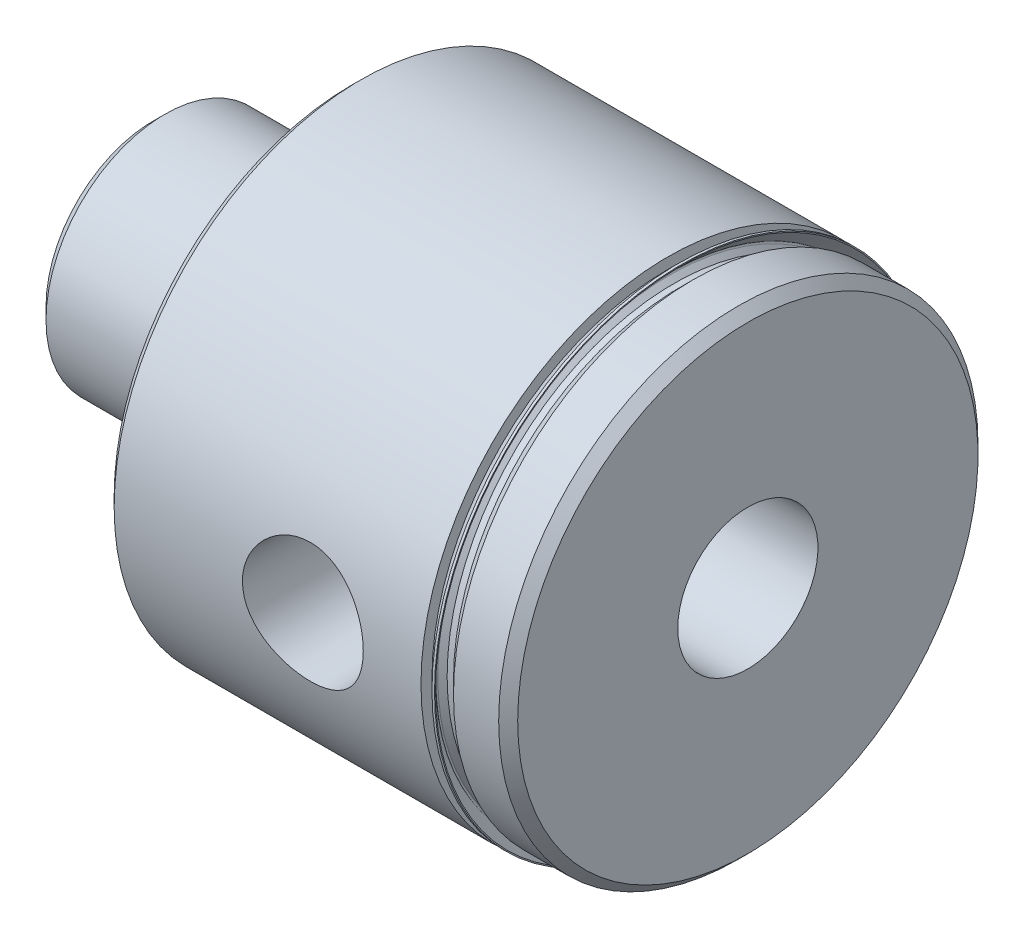
from build123d import *


with BuildPart() as part:
    # Sketch1 → Revolve1 (revolve)
    with BuildSketch(Plane.XY):
        with BuildLine():
            Line((0, 0), (0, 8.58901))
            Line((0, 8.58901), (0.93599, 9.525))
            Line((0.93599, 9.525), (9.310047461, 9.525))
            Line((9.310047461, 9.525), (10.262333187, 8.610821042))
            ThreePointArc((10.262333187, 8.610821042), (10.619173954, 8.380210754), (11.0363, 8.29945))
            Line((11.0363, 8.29945), (12.3698, 8.29945))
            ThreePointArc((12.3698, 8.29945), (13.160062539, 8.626787461), (13.4874, 9.41705))
            Line((13.4874, 9.41705), (13.4874, 9.49325))
            Line((13.4874, 9.49325), (15.875, 9.49325))
            Line((15.875, 9.49325), (15.875, 0))
            Line((15.875, 0), (0, 0))
        make_face()
    revolve(axis=Axis((15.875, 0, 0), (-1, 0, 0)))

    # Sketch2 → Revolve2 (revolve)
    with BuildSketch(Plane.XY):
        Polygon((15.875, 0), (15.875, 19.00555), (16.637, 19.76755), (41.2115, 19.76755), (41.2115, 18.18005), (42.2275, 18.18005), (43.2435, 19.19605), (46.863, 19.19605), (47.625, 18.43405), (47.625, 0), align=None)
    revolve(axis=Axis((47.625, 0, 0), (-1, 0, 0)))

    # Sketch3 → Cut-Revolve1 (revolve, cut)
    with BuildSketch(Plane.XY):
        Polygon((0, 0), (0, 6.3754), (0.762, 5.6134), (47.625, 5.6134), (47.625, 0), align=None)
    revolve(axis=Axis((47.625, 0, 0), (-1, 0, 0)), mode=Mode.SUBTRACT)

    # Sketch4 → Cut-Revolve2 (revolve, cut)
    with BuildSketch(Plane(origin=(0, 0, 0), x_dir=(1, 0, 0), z_dir=(0, 1, 0))):
        Polygon((31.75, 0), (34.925, 0), (34.925, -7.768124148), (36.256425852, -9.09955), (36.589475925, -19.76755), (31.75, -19.76755), align=None)
    revolve(axis=Axis((31.75, 0, 19.76755), (0, 0, -1)), mode=Mode.SUBTRACT)

    # Sketch5 → Revolve3 (revolve)
    with BuildSketch(Plane.XY):
        with BuildLine():
            Line((41.2115, 18.888259175), (41.2115, 17.92605))
            Line((41.2115, 17.92605), (42.2275, 17.92605))
            Line((42.2275, 17.92605), (42.2275, 18.18005))
            Line((42.2275, 18.18005), (41.7195, 18.18005))
            Line((41.7195, 18.18005), (41.344882072, 18.554667928))
            ThreePointArc((41.344882072, 18.554667928), (41.307684633, 18.64447049), (41.344882072, 18.734273051))
            Line((41.344882072, 18.734273051), (42.293990825, 19.683381804))
            Line((42.293990825, 19.683381804), (42.293990825, 19.76755))
            Line((42.293990825, 19.76755), (42.090790825, 19.76755))
            Line((42.090790825, 19.76755), (41.2115, 18.888259175))
        make_face()
    revolve(axis=Axis((42.2275, 0, 0), (-1, 0, 0)))


solid = part.part
